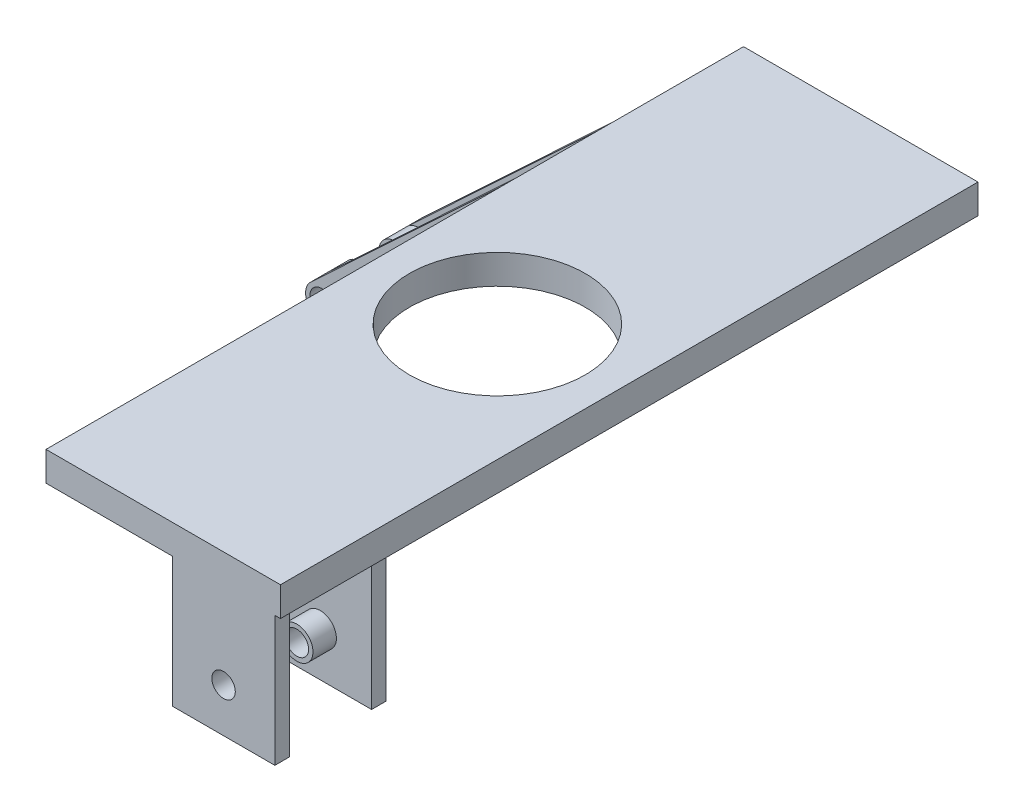
from build123d import *

# Parameters (mm, degrees)
SKETCH1_R                = 30
SKETCH1_W                = 35
SKETCH1_H                = 5
SKETCH1_H_2              = 28
BOSS_EXTRUDE1_DEPTH      = 10
SKETCH2_W                = 35
SKETCH2_H                = 44.33
SKETCH2_R                = 5.5
BOSS_EXTRUDE2_DEPTH      = 19
BOSS_EXTRUDE2_DEPTH_BACK = 19
SKETCH2_4_R              = 4
SKETCH2_4_W              = 35
SKETCH2_4_H              = 44.33
SKETCH2_4_R_2            = 5.5
CUT_EXTRUDE1_DEPTH       = 14
SKETCH3_W                = 35
SKETCH3_H                = 30
SKETCH3_R                = 5.5
BOSS_EXTRUDE3_DEPTH      = 19
SKETCH3_3_R              = 4
SKETCH3_3_W              = 35
SKETCH3_3_H              = 30
SKETCH3_3_R_2            = 5.5
CUT_EXTRUDE2_DEPTH       = 14
SKETCH2_5_R              = 5.5
SKETCH2_5_R_2            = 4
BOSS_EXTRUDE4_DEPTH      = 19
SKETCH2_6_R              = 5.5
SKETCH2_6_R_2            = 4
CUT_EXTRUDE3_DEPTH       = 6
SKETCH3_4_R              = 5.5
SKETCH3_4_R_2            = 4
BOSS_EXTRUDE5_DEPTH      = 19
SKETCH3_5_R              = 5.5
SKETCH3_5_R_2            = 4
CUT_EXTRUDE4_DEPTH       = 6
SKETCH5_R                = 4
BOSS_EXTRUDE6_DEPTH      = 19
CUT_EXTRUDE5_DEPTH       = 14
SKETCH5_6_R              = 5.5
SKETCH5_6_R_2            = 4
CUT_EXTRUDE6_DEPTH       = 6


with BuildPart() as part:
    # Sketch1 → Boss-Extrude1 (new body)
    with BuildSketch(Plane(origin=(0, 580, 0), x_dir=(1, 0, 0), z_dir=(0, 1, 0))):
        Polygon((677.75, 14), (692.03, 14), (692.03, 9), (692.03, -19), (692.03, -24), (727.03, -24), (727.03, -19), (727.03, 9), (727.03, 14), (757.75, 14), (757.75, -224), (755.84, -224), (755.84, -219), (755.84, -191), (755.84, -186), (720.84, -186), (720.84, -191), (720.84, -219), (720.84, -224), (677.75, -224), align=None)
        with Locations((717.75, -110)):
            Circle(SKETCH1_R, mode=Mode.SUBTRACT)
        with Locations((709.53, 11.5)):
            Rectangle(SKETCH1_W, SKETCH1_H)
        with Locations((709.53, -5)):
            Rectangle(SKETCH1_W, SKETCH1_H_2)
        with Locations((709.53, -21.5)):
            Rectangle(SKETCH1_W, SKETCH1_H)
        with Locations((738.34, -188.5)):
            Rectangle(SKETCH1_W, SKETCH1_H)
        with Locations((738.34, -205)):
            Rectangle(SKETCH1_W, SKETCH1_H_2)
        with Locations((738.34, -221.5)):
            Rectangle(SKETCH1_W, SKETCH1_H)
    extrude(amount=BOSS_EXTRUDE1_DEPTH)

    # Sketch2 → Boss-Extrude2 (add, two sides)
    with BuildSketch(Plane.XY.offset(205)) as boss_extrude2_sk:
        with Locations((738.34, 557.835)):
            Rectangle(SKETCH2_W, SKETCH2_H)
        with Locations((738.34, 550.67)):
            Circle(SKETCH2_R, mode=Mode.SUBTRACT)
    extrude(amount=BOSS_EXTRUDE2_DEPTH)
    extrude(boss_extrude2_sk.sketch, amount=-BOSS_EXTRUDE2_DEPTH_BACK)

    # Sketch2_4 → Cut-Extrude1 (cut, symmetric)
    with BuildSketch(Plane.XY.offset(205)):
        with Locations((738.34, 550.67)):
            Circle(SKETCH2_4_R)
        with Locations((738.34, 557.835)):
            Rectangle(SKETCH2_4_W, SKETCH2_4_H)
        with Locations((738.34, 550.67)):
            Circle(SKETCH2_4_R_2, mode=Mode.SUBTRACT)
    extrude(amount=CUT_EXTRUDE1_DEPTH, both=True, mode=Mode.SUBTRACT)

    # Sketch3 → Boss-Extrude3 (add, symmetric)
    with BuildSketch(Plane.XY.offset(5)):
        with Locations((709.53, 565)):
            Rectangle(SKETCH3_W, SKETCH3_H)
        with Locations((709.53, 565)):
            Circle(SKETCH3_R, mode=Mode.SUBTRACT)
    extrude(amount=BOSS_EXTRUDE3_DEPTH, both=True)

    # Sketch3_3 → Cut-Extrude2 (cut, symmetric)
    with BuildSketch(Plane.XY.offset(5)):
        with Locations((709.53, 565)):
            Circle(SKETCH3_3_R)
        with Locations((709.53, 565)):
            Rectangle(SKETCH3_3_W, SKETCH3_3_H)
        with Locations((709.53, 565)):
            Circle(SKETCH3_3_R_2, mode=Mode.SUBTRACT)
    extrude(amount=CUT_EXTRUDE2_DEPTH, both=True, mode=Mode.SUBTRACT)

    # Sketch2_5 → Boss-Extrude4 (add, symmetric)
    with BuildSketch(Plane.XY.offset(205)):
        with Locations((738.34, 550.67)):
            Circle(SKETCH2_5_R)
        with Locations((738.34, 550.67)):
            Circle(SKETCH2_5_R_2, mode=Mode.SUBTRACT)
    extrude(amount=BOSS_EXTRUDE4_DEPTH, both=True)

    # Sketch2_6 → Cut-Extrude3 (cut, symmetric)
    with BuildSketch(Plane.XY.offset(205)):
        with Locations((738.34, 550.67)):
            Circle(SKETCH2_6_R)
        with Locations((738.34, 550.67)):
            Circle(SKETCH2_6_R_2, mode=Mode.SUBTRACT)
    extrude(amount=CUT_EXTRUDE3_DEPTH, both=True, mode=Mode.SUBTRACT)

    # Sketch3_4 → Boss-Extrude5 (add, symmetric)
    with BuildSketch(Plane.XY.offset(5)):
        with Locations((709.53, 565)):
            Circle(SKETCH3_4_R)
        with Locations((709.53, 565)):
            Circle(SKETCH3_4_R_2, mode=Mode.SUBTRACT)
    extrude(amount=BOSS_EXTRUDE5_DEPTH, both=True)

    # Sketch3_5 → Cut-Extrude4 (cut, symmetric)
    with BuildSketch(Plane.XY.offset(5)):
        with Locations((709.53, 565)):
            Circle(SKETCH3_5_R)
        with Locations((709.53, 565)):
            Circle(SKETCH3_5_R_2, mode=Mode.SUBTRACT)
    extrude(amount=CUT_EXTRUDE4_DEPTH, both=True, mode=Mode.SUBTRACT)

    # Sketch5 → Boss-Extrude6 (add, symmetric)
    with BuildSketch(Plane.XY.offset(49.7)):
        with BuildLine():
            Line((677.75, 580), (677.75, 590))
            Line((677.75, 590), (612.765312184, 529.288994825))
            ThreePointArc((612.765312184, 529.288994825), (612.586521385, 521.425816604), (620.451731788, 521.424030013))
            Line((620.451731788, 521.424030013), (677.75, 580))
        make_face()
        with Locations((616.52, 525.27)):
            Circle(SKETCH5_R, mode=Mode.SUBTRACT)
    extrude(amount=BOSS_EXTRUDE6_DEPTH, both=True)

    # Sketch5_5 → Cut-Extrude5 (cut, symmetric)
    with BuildSketch(Plane.XY.offset(49.7)):
        with BuildLine():
            Line((677.75, 580), (677.75, 590))
            Line((677.75, 590), (612.765312184, 529.288994825))
            ThreePointArc((612.765312184, 529.288994825), (618.710800882, 530.314838104), (622.02, 525.27))
            ThreePointArc((622.02, 525.27), (621.612863872, 523.193286832), (620.451731788, 521.424030013))
            Line((620.451731788, 521.424030013), (677.75, 580))
        make_face()
    extrude(amount=CUT_EXTRUDE5_DEPTH, both=True, mode=Mode.SUBTRACT)

    # Sketch5_6 → Cut-Extrude6 (cut, symmetric)
    with BuildSketch(Plane.XY.offset(49.7)):
        with Locations((616.52, 525.27)):
            Circle(SKETCH5_6_R)
        with Locations((616.52, 525.27)):
            Circle(SKETCH5_6_R_2, mode=Mode.SUBTRACT)
    extrude(amount=CUT_EXTRUDE6_DEPTH, both=True, mode=Mode.SUBTRACT)


solid = part.part
